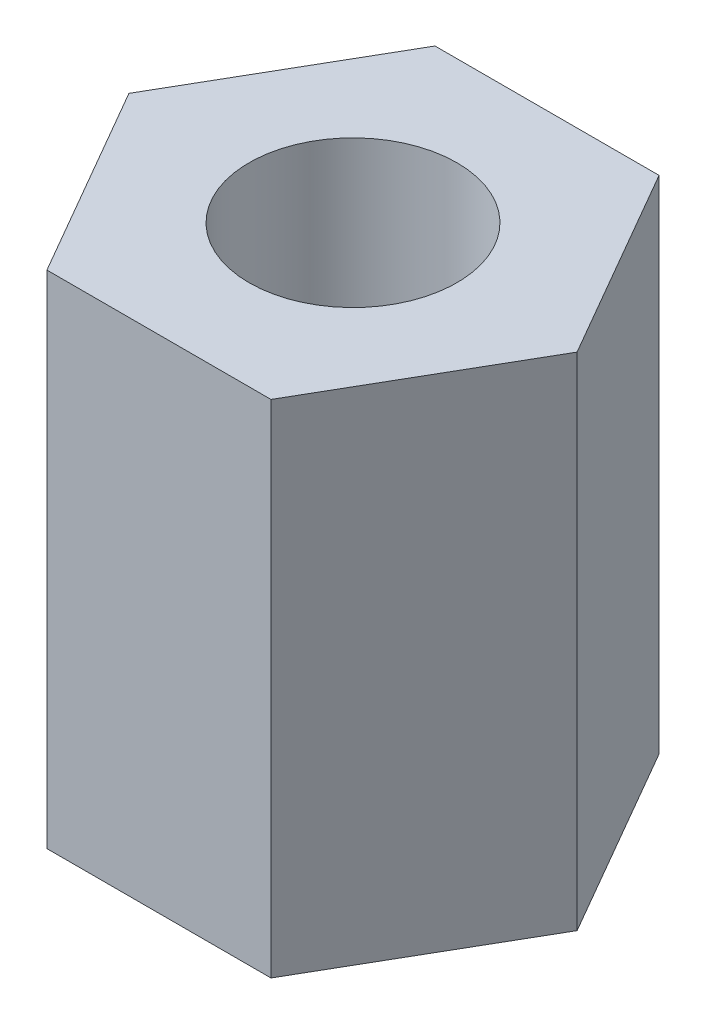
from build123d import *

# Parameters (mm, degrees)
SKETCH_1_R      = 1.5
EXTRUDE_1_DEPTH = 7.23


with BuildPart() as part:
    # 草图1 → 凸台-拉伸1 (new body)
    with BuildSketch(Plane(origin=(0, 0, 0), x_dir=(1, 0, 0), z_dir=(0, 1, 0))):
        Polygon((3.233161507, 0), (1.616580754, 2.8), (-1.616580754, 2.8), (-3.233161507, 0), (-1.616580754, -2.8), (1.616580754, -2.8), align=None)
        Circle(SKETCH_1_R, mode=Mode.SUBTRACT)
    extrude(amount=EXTRUDE_1_DEPTH)


solid = part.part
